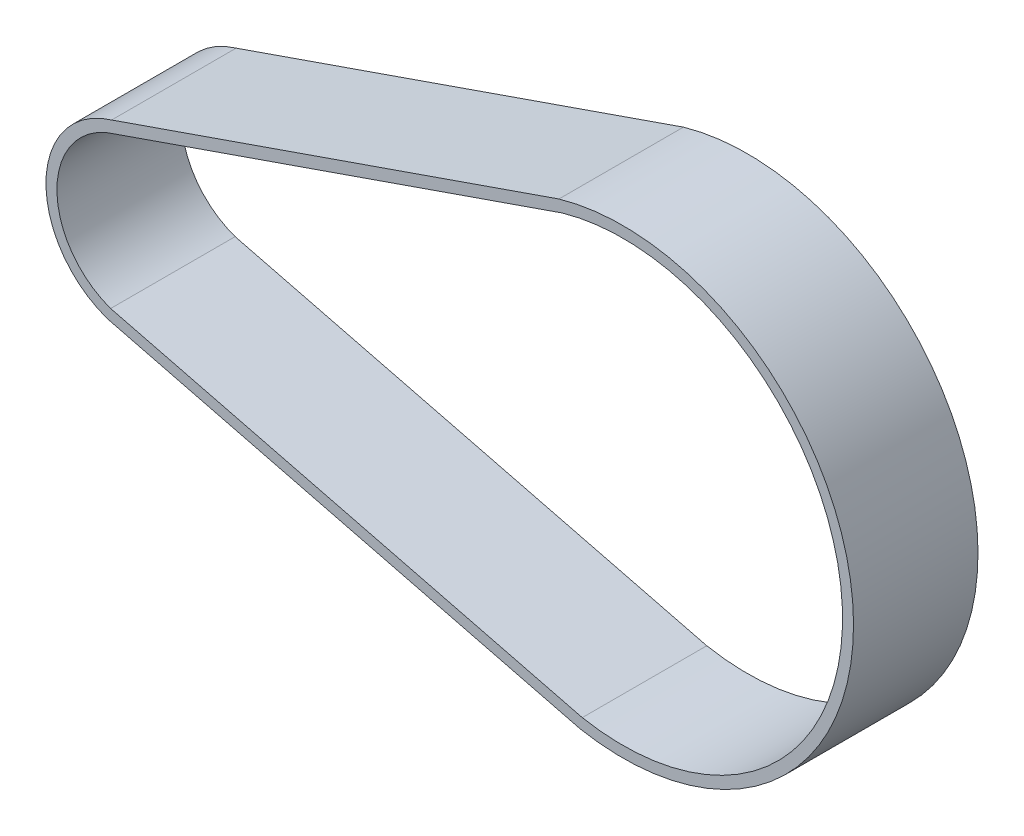
from build123d import *

# Parameters (mm, degrees)
BOSS_EXTRUDE1_DEPTH = 17


with BuildPart() as part:
    # Sketch1 → Boss-Extrude1 (new body)
    with BuildSketch(Plane.XY):
        with BuildLine():
            Line((-3.527153581, 11.992046848), (57.563154087, 33.193430447))
            ThreePointArc((57.563154087, 33.193430447), (97.7607975, 4.400287956), (60.427541244, -28.020747929))
            Line((60.427541244, -28.020747929), (-4.093669967, -11.810667475))
            ThreePointArc((-4.093669967, -11.810667475), (-12.496461106, 0.297421962), (-3.527153581, 11.992046848))
        make_face()
        with BuildLine():
            Line((-3.070448196, 10.562781257), (58.016821264, 31.763110445))
            ThreePointArc((58.016821264, 31.763110445), (96.26233961, 4.332254849), (60.7497527, -26.55508371))
            Line((60.7497527, -26.55508371), (-3.662441577, -10.372392284))
            ThreePointArc((-3.662441577, -10.372392284), (-10.995604757, 0.310927694), (-3.070448196, 10.562781257))
        make_face(mode=Mode.SUBTRACT)
    extrude(amount=BOSS_EXTRUDE1_DEPTH)


solid = part.part
